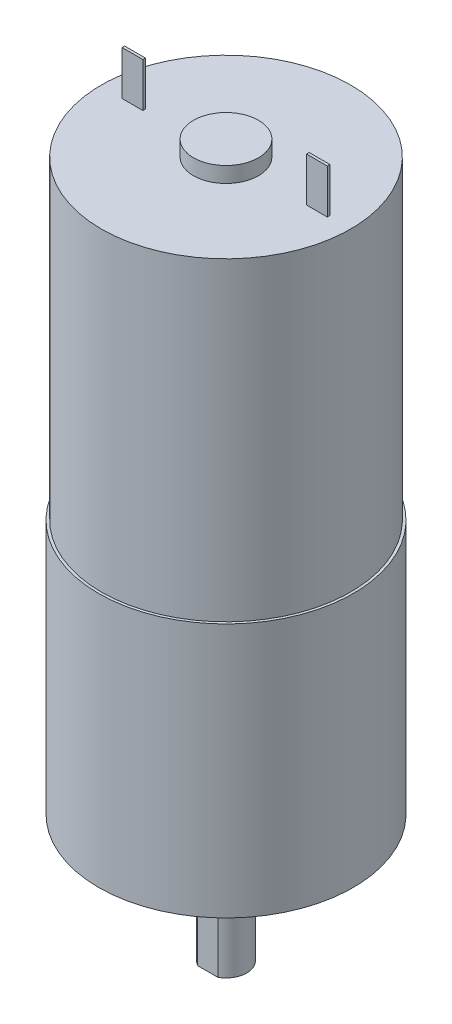
from build123d import *

# Parameters (mm, degrees)
SKETCH1_R                                       = 12.446
SKETCH1_R_2                                     = 1.27
BOSS_EXTRUDE1_DEPTH                             = 24.892
CSK_FOR_M3_FLAT_HEAD_MACHINE_SCREW1_D           = 3.4
CSK_FOR_M3_FLAT_HEAD_MACHINE_SCREW1_CSINK_D     = 6.3
CSK_FOR_M3_FLAT_HEAD_MACHINE_SCREW1_CSINK_ANGLE = 90
SKETCH5_R                                       = 12.192
BOSS_EXTRUDE2_DEPTH                             = 30.734
SKETCH6_R                                       = 3.556
BOSS_EXTRUDE3_DEPTH                             = 2.54
SKETCH7_R                                       = 2.032
BOSS_EXTRUDE4_DEPTH                             = 9.906
SKETCH8_W                                       = 2.032
SKETCH8_H                                       = 0.254
CUT_EXTRUDE2_DEPTH                              = 9.906
SKETCH9_R                                       = 3.175
BOSS_EXTRUDE5_DEPTH                             = 1.524
SKETCH10_W                                      = 2.032
SKETCH10_H                                      = 0.254
BOSS_EXTRUDE6_DEPTH                             = 4.318


with BuildPart() as part:
    # Sketch1 → Boss-Extrude1 (new body)
    with BuildSketch(Plane(origin=(0, 0, 0), x_dir=(1, 0, 0), z_dir=(0, 1, 0))):
        Circle(SKETCH1_R)
        with Locations((-9.017, 0)):
            Circle(SKETCH1_R_2, mode=Mode.SUBTRACT)
        with Locations((9.017, 0)):
            Circle(SKETCH1_R_2, mode=Mode.SUBTRACT)
    extrude(amount=BOSS_EXTRUDE1_DEPTH)

    # CSK for M3 Flat Head Machine Screw1 (through all)
    with Locations(Plane(origin=(0, 24.892, 0), x_dir=(1, 0, 0), z_dir=(0, 1, 0))):
        with Locations((0, 8.119865968), (0, -7.587036194)):
            CounterSinkHole(CSK_FOR_M3_FLAT_HEAD_MACHINE_SCREW1_D / 2, CSK_FOR_M3_FLAT_HEAD_MACHINE_SCREW1_CSINK_D / 2, counter_sink_angle=CSK_FOR_M3_FLAT_HEAD_MACHINE_SCREW1_CSINK_ANGLE)

    # Sketch5 → Boss-Extrude2 (add)
    with BuildSketch(Plane(origin=(0, 24.892, 0), x_dir=(1, 0, 0), z_dir=(0, 1, 0))):
        Circle(SKETCH5_R)
    extrude(amount=BOSS_EXTRUDE2_DEPTH)

    # Sketch6 → Boss-Extrude3 (add)
    with BuildSketch(Plane(origin=(0, 0, 0), x_dir=(1, 0, 0), z_dir=(0, 1, 0))):
        Circle(SKETCH6_R)
    extrude(amount=-BOSS_EXTRUDE3_DEPTH)

    # Sketch7 → Boss-Extrude4 (add)
    with BuildSketch(Plane(origin=(0, -2.54, 0), x_dir=(-1, 0, 0), z_dir=(0, -1, 0))):
        Circle(SKETCH7_R)
    extrude(amount=BOSS_EXTRUDE4_DEPTH)

    # Sketch8 → Cut-Extrude2 (cut)
    with BuildSketch(Plane(origin=(0, -12.446, 0), x_dir=(-1, 0, 0), z_dir=(0, -1, 0))):
        with Locations((0, -1.905)):
            Rectangle(SKETCH8_W, SKETCH8_H)
        with Locations((0, 1.905)):
            Rectangle(SKETCH8_W, SKETCH8_H)
    extrude(amount=-CUT_EXTRUDE2_DEPTH, mode=Mode.SUBTRACT)

    # Sketch9 → Boss-Extrude5 (add)
    with BuildSketch(Plane(origin=(0, 55.626, 0), x_dir=(1, 0, 0), z_dir=(0, 1, 0))):
        Circle(SKETCH9_R)
    extrude(amount=BOSS_EXTRUDE5_DEPTH)

    # Sketch10 → Boss-Extrude6 (add)
    with BuildSketch(Plane(origin=(0, 55.626, 0), x_dir=(1, 0, 0), z_dir=(0, 1, 0))):
        with Locations((-9.017, 0)):
            Rectangle(SKETCH10_W, SKETCH10_H)
        with Locations((9.017, 0)):
            Rectangle(SKETCH10_W, SKETCH10_H)
    extrude(amount=BOSS_EXTRUDE6_DEPTH)


solid = part.part
